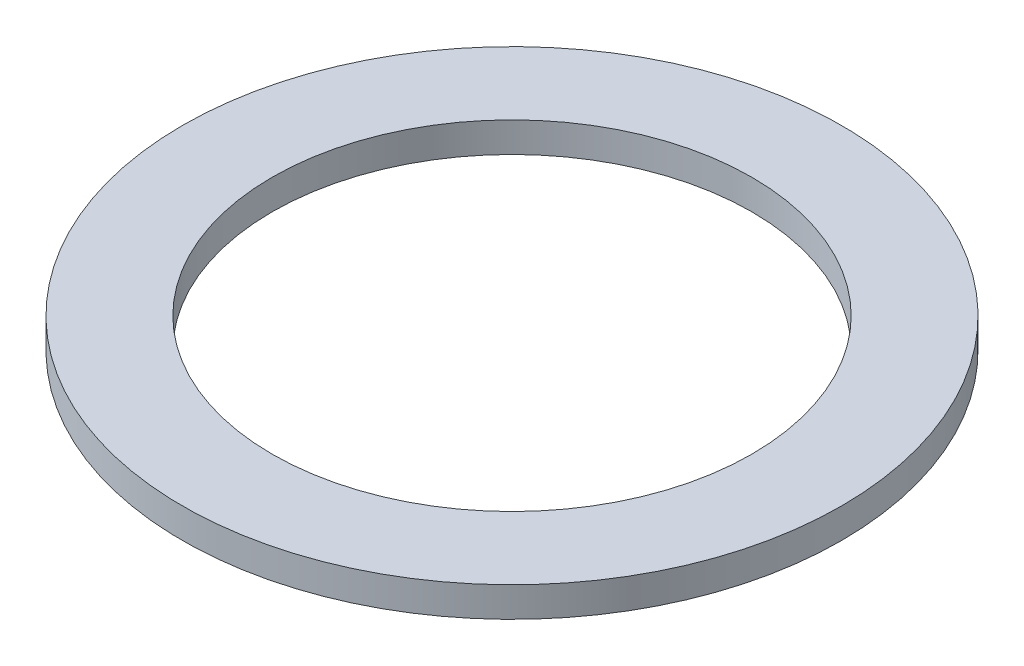
from build123d import *

# Parameters (mm, degrees)
SKETCH1_W = 9.4996
SKETCH1_H = 3.175


with BuildPart() as part:
    # Sketch1 → Revolve1 (revolve)
    with BuildSketch(Plane.XY):
        with Locations((-30.1498, 1.5875)):
            Rectangle(SKETCH1_W, SKETCH1_H)
    revolve(axis=Axis((0, 0, 0), (0, 1, 0)))


solid = part.part
